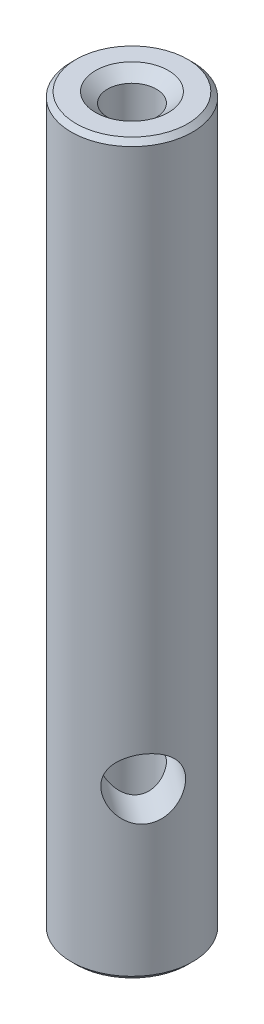
from build123d import *

# Parameters (mm, degrees)
F_1_4_20_TAPPED_HOLE1_D           = 5.1054
F_1_4_20_TAPPED_HOLE1_DEPTH       = 76.2
F_1_4_20_TAPPED_HOLE1_CSINK_D     = 7.62
F_1_4_20_TAPPED_HOLE1_CSINK_ANGLE = 100
F_1_4_0_25_DIAMETER_HOLE1_D       = 6.35


with BuildPart() as part:
    # Sketch1 → Revolve1 (revolve)
    with BuildSketch(Plane(origin=(0, 0, 0), x_dir=(-1, 0, 0), z_dir=(0, 0, -1))):
        Polygon((-5.83819, 0), (0, 0), (0, 76.2), (-5.83819, 76.2), (-6.34619, 75.692), (-6.34619, 0.508), align=None)
    revolve(axis=Axis((0, 0, 0), (0, 1, 0)))

    # 1/4-20 Tapped Hole1
    with Locations(Plane(origin=(0, 76.2, 0), x_dir=(1, 0, 0), z_dir=(0, 1, 0))):
        with Locations((0, 0)):
            CounterSinkHole(F_1_4_20_TAPPED_HOLE1_D / 2, F_1_4_20_TAPPED_HOLE1_CSINK_D / 2, depth=F_1_4_20_TAPPED_HOLE1_DEPTH, counter_sink_angle=F_1_4_20_TAPPED_HOLE1_CSINK_ANGLE)

    # 1/4 (0.25) Diameter Hole1 (through all)
    with Locations(Plane(origin=(-5.114677075, 17.430811078, -3.756887799), x_dir=(0.591991068, 0, -0.805944523), z_dir=(-0.805944523, 0, -0.591991068))):
        with Locations((0, 0)):
            Hole(F_1_4_0_25_DIAMETER_HOLE1_D / 2)


solid = part.part
